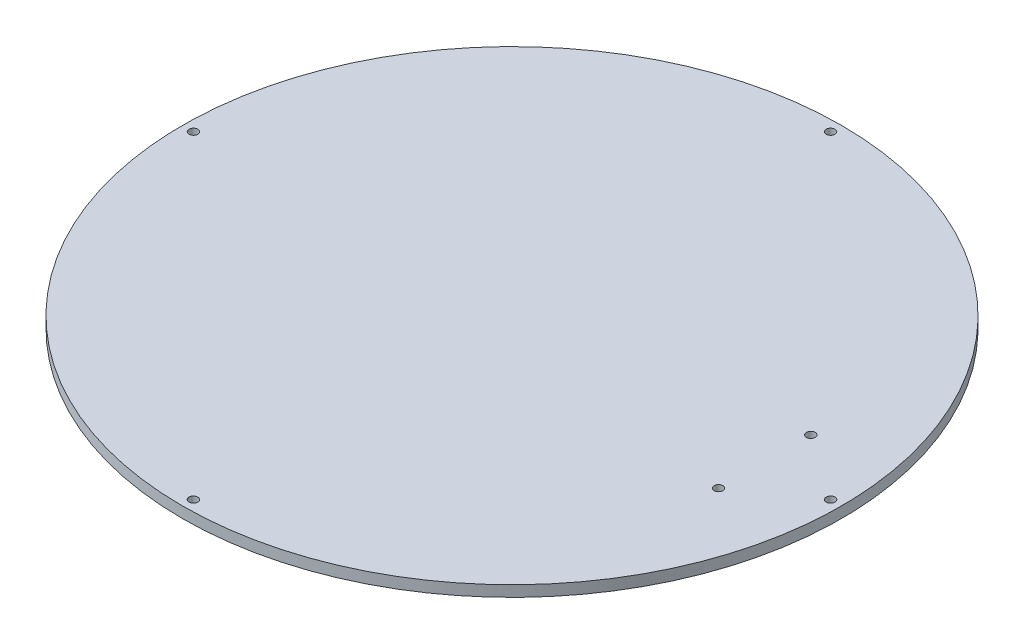
from build123d import *

# Parameters (mm, degrees)
SKETCH1_R           = 300
BOSS_EXTRUDE1_DEPTH = 10
SKETCH3_R           = 4
CUT_EXTRUDE1_DEPTH  = 11


with BuildPart() as part:
    # Sketch1 → Boss-Extrude1 (new body)
    with BuildSketch(Plane(origin=(0, 0, 0), x_dir=(1, 0, 0), z_dir=(0, 1, 0))):
        Circle(SKETCH1_R)
    extrude(amount=BOSS_EXTRUDE1_DEPTH)

    # Sketch3 → Cut-Extrude1 (cut, through all)
    with BuildSketch(Plane(origin=(0, 10, 0), x_dir=(1, 0, 0), z_dir=(0, 1, 0))):
        with Locations((290, 0)):
            Circle(SKETCH3_R)
        with Locations((0, -290)):
            Circle(SKETCH3_R)
        with Locations((-290, 0)):
            Circle(SKETCH3_R)
        with Locations((0, 290)):
            Circle(SKETCH3_R)
        with Locations((230, -42)):
            Circle(SKETCH3_R)
        with Locations((230, 42)):
            Circle(SKETCH3_R)
    extrude(amount=-CUT_EXTRUDE1_DEPTH, mode=Mode.SUBTRACT)


solid = part.part
